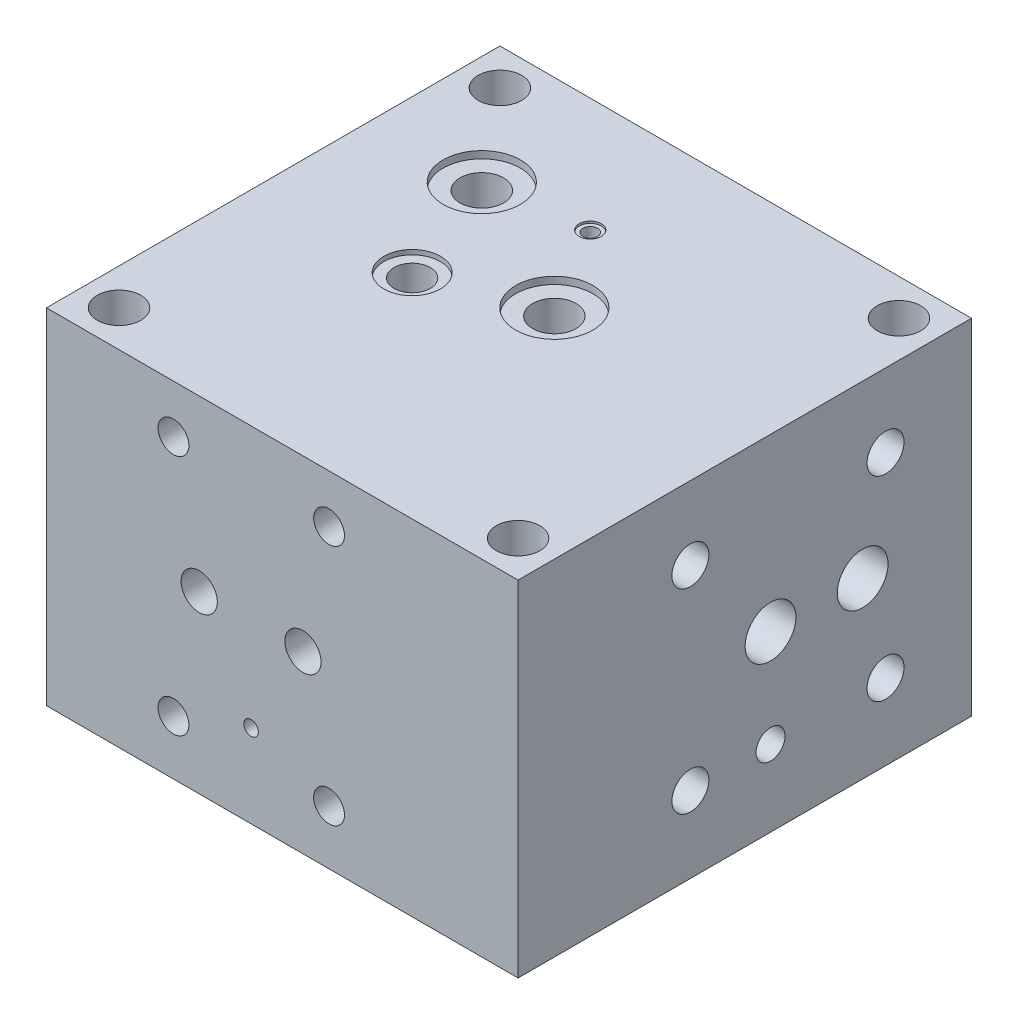
from build123d import *

# Parameters (mm, degrees)
SKETCH_1_W               = 130
SKETCH_1_H               = 125
EXTRUDE_2_DEPTH          = 95
SKETCH_2_R               = 6
CUT_EXTRUDE_1_DEPTH      = 96
SKETCH_3_R               = 6
CUT_EXTRUDE_2_DEPTH      = 95
SKETCH_4_R               = 10.65
CUT_EXTRUDE_3_DEPTH      = 1.97
SKETCH_5_R               = 6
CUT_EXTRUDE_5_DEPTH      = 94.03
SKETCH_6_R               = 10.65
CUT_EXTRUDE_6_DEPTH      = 1.97
SKETCH_7_R               = 6
CUT_EXTRUDE_7_DEPTH      = 94.03
SKETCH_8_R               = 7.8
CUT_EXTRUDE_8_DEPTH      = 1.28
MM_1_D                   = 10
MM_1_DEPTH               = 49.73
MM_1_TIP                 = 3.004303095
HOLE_WIZARD_M10_2_D      = 8.5
HOLE_WIZARD_M10_2_DEPTH  = 14
HOLE_WIZARD_M10_2_TIP    = 2.553657631
HOLE_WIZARD_M10_3_D      = 8.5
HOLE_WIZARD_M10_3_DEPTH  = 14
HOLE_WIZARD_M10_3_TIP    = 2.553657631
HOLE_WIZARD_M10_4_D      = 8.5
HOLE_WIZARD_M10_4_DEPTH  = 14
HOLE_WIZARD_M10_4_TIP    = 2.553657631
HOLE_WIZARD_M10_5_D      = 8.5
HOLE_WIZARD_M10_5_DEPTH  = 14
HOLE_WIZARD_M10_5_TIP    = 2.553657631
MM_2_D                   = 8
MM_2_DEPTH               = 10
MM_2_TIP                 = 2.403442476
CUT_EXTRUDE_9_REACH      = 132
SKETCH_17_R              = 5
MM_4_D                   = 10
MM_4_DEPTH               = 47
MM_4_TIP                 = 3.004303095
HOLE_WIZARD_M10_7_D      = 8.5
HOLE_WIZARD_M10_7_DEPTH  = 14
HOLE_WIZARD_M10_7_TIP    = 2.553657631
HOLE_WIZARD_M10_8_D      = 8.5
HOLE_WIZARD_M10_8_DEPTH  = 14
HOLE_WIZARD_M10_8_TIP    = 2.553657631
HOLE_WIZARD_M10_9_D      = 8.5
HOLE_WIZARD_M10_9_DEPTH  = 14
HOLE_WIZARD_M10_9_TIP    = 2.553657631
HOLE_WIZARD_M10_10_D     = 8.5
HOLE_WIZARD_M10_10_DEPTH = 14
HOLE_WIZARD_M10_10_TIP   = 2.553657631
CUT_EXTRUDE_10_REACH     = 127
SKETCH_27_R              = 5
CUT_EXTRUDE_11_REACH     = 127
SKETCH_28_R              = 5
HOLE_WIZARD_M12_1_D      = 10.2
HOLE_WIZARD_M12_1_DEPTH  = 18
HOLE_WIZARD_M12_1_TIP    = 3.064389157
HOLE_WIZARD_M12_2_D      = 10.2
HOLE_WIZARD_M12_2_DEPTH  = 18
HOLE_WIZARD_M12_2_TIP    = 3.064389157
HOLE_WIZARD_M12_3_D      = 10.2
HOLE_WIZARD_M12_3_DEPTH  = 18
HOLE_WIZARD_M12_3_TIP    = 3.064389157
HOLE_WIZARD_M12_4_D      = 10.2
HOLE_WIZARD_M12_4_DEPTH  = 18
HOLE_WIZARD_M12_4_TIP    = 3.064389157
MM_5_D                   = 14
MM_5_DEPTH               = 60
MM_5_TIP                 = 4.206024333
MM_6_D                   = 14
MM_6_DEPTH               = 100
MM_6_TIP                 = 4.206024333
MM_9_D                   = 8
MM_9_DEPTH               = 10
MM_9_TIP                 = 2.403442476
CUT_EXTRUDE_12_REACH     = 127
SKETCH_44_R              = 2
HOLE_WIZARD_M10_11_D     = 8.5
HOLE_WIZARD_M10_11_DEPTH = 14
HOLE_WIZARD_M10_11_TIP   = 2.553657631
SKETCH_46_R              = 3.05
CUT_EXTRUDE_13_DEPTH     = 0.56
MM_10_D                  = 4
MM_10_DEPTH              = 71
MM_10_TIP                = 1.201721238
MM_11_D                  = 4
MM_11_DEPTH              = 95
MM_11_TIP                = 1.201721238


with BuildPart() as part:
    # 草图1 → 凸台-拉伸2 (new body)
    with BuildSketch(Plane(origin=(0, 0, 0), x_dir=(1, 0, 0), z_dir=(0, 1, 0))):
        Rectangle(SKETCH_1_W, SKETCH_1_H)
    extrude(amount=EXTRUDE_2_DEPTH)

    # 草图2 → 切除-拉伸1 (cut, through all)
    with BuildSketch(Plane(origin=(0, 95, 0), x_dir=(1, 0, 0), z_dir=(0, 1, 0))):
        with Locations((-55, 52.5)):
            Circle(SKETCH_2_R)
        with Locations((55, 52.5)):
            Circle(SKETCH_2_R)
        with Locations((-55, -52.5)):
            Circle(SKETCH_2_R)
    extrude(amount=-CUT_EXTRUDE_1_DEPTH, mode=Mode.SUBTRACT)

    # 草图3 → 切除-拉伸2 (cut)
    with BuildSketch(Plane(origin=(0, 95, 0), x_dir=(1, 0, 0), z_dir=(0, 1, 0))):
        with Locations((55, -52.5)):
            Circle(SKETCH_3_R)
    extrude(amount=-CUT_EXTRUDE_2_DEPTH, mode=Mode.SUBTRACT)

    # 草图4 → 切除-拉伸3 (cut)
    with BuildSketch(Plane(origin=(0, 95, 0), x_dir=(1, 0, 0), z_dir=(0, 1, 0))):
        with Locations((-35, 27.5)):
            Circle(SKETCH_4_R)
    extrude(amount=-CUT_EXTRUDE_3_DEPTH, mode=Mode.SUBTRACT)

    # 草图5 → 切除-拉伸5 (cut, through all)
    with BuildSketch(Plane(origin=(0, 93.03, 0), x_dir=(1, 0, 0), z_dir=(0, 1, 0))):
        with Locations((-35, 27.5)):
            Circle(SKETCH_5_R)
    extrude(amount=-CUT_EXTRUDE_5_DEPTH, mode=Mode.SUBTRACT)

    # 草图6 → 切除-拉伸6 (cut)
    with BuildSketch(Plane(origin=(0, 95, 0), x_dir=(1, 0, 0), z_dir=(0, 1, 0))):
        with Locations((5, 7.5)):
            Circle(SKETCH_6_R)
    extrude(amount=-CUT_EXTRUDE_6_DEPTH, mode=Mode.SUBTRACT)

    # 草图7 → 切除-拉伸7 (cut, through all)
    with BuildSketch(Plane(origin=(0, 93.03, 0), x_dir=(1, 0, 0), z_dir=(0, 1, 0))):
        with Locations((5, 7.5)):
            Circle(SKETCH_7_R)
    extrude(amount=-CUT_EXTRUDE_7_DEPTH, mode=Mode.SUBTRACT)

    # 草图8 → 切除-拉伸8 (cut)
    with BuildSketch(Plane(origin=(0, 95, 0), x_dir=(1, 0, 0), z_dir=(0, 1, 0))):
        with Locations((-23, -3.7)):
            Circle(SKETCH_8_R)
    extrude(amount=-CUT_EXTRUDE_8_DEPTH, mode=Mode.SUBTRACT)

    # 大小mm 暗销孔1
    with Locations(Plane(origin=(-23, 93.72, 3.7), x_dir=(0, 0, 1), z_dir=(0, 1, 0))):
        with Locations((0, 0)):
            Hole(MM_1_D / 2, depth=MM_1_DEPTH)
            with Locations((0, 0, -(MM_1_DEPTH + MM_1_TIP / 2))):  # 118° drill point
                Cone(0, MM_1_D / 2, MM_1_TIP, mode=Mode.SUBTRACT)

    # M10 螺纹孔2
    with Locations(Plane(origin=(-65, 81.7, 39.4), x_dir=(0, 0, -1), z_dir=(-1, 0, 0))):
        with Locations((0, 0)):
            Hole(HOLE_WIZARD_M10_2_D / 2, depth=HOLE_WIZARD_M10_2_DEPTH)
            with Locations((0, 0, -(HOLE_WIZARD_M10_2_DEPTH + HOLE_WIZARD_M10_2_TIP / 2))):  # 118° drill point
                Cone(0, HOLE_WIZARD_M10_2_D / 2, HOLE_WIZARD_M10_2_TIP, mode=Mode.SUBTRACT)

    # M10 螺纹孔3
    with Locations(Plane(origin=(-65, 81.7, -3.5), x_dir=(0, 0, -1), z_dir=(-1, 0, 0))):
        with Locations((0, 0)):
            Hole(HOLE_WIZARD_M10_3_D / 2, depth=HOLE_WIZARD_M10_3_DEPTH)
            with Locations((0, 0, -(HOLE_WIZARD_M10_3_DEPTH + HOLE_WIZARD_M10_3_TIP / 2))):  # 118° drill point
                Cone(0, HOLE_WIZARD_M10_3_D / 2, HOLE_WIZARD_M10_3_TIP, mode=Mode.SUBTRACT)

    # M10 螺纹孔4
    with Locations(Plane(origin=(-65, 15, 39.4), x_dir=(0, 0, -1), z_dir=(-1, 0, 0))):
        with Locations((0, 0)):
            Hole(HOLE_WIZARD_M10_4_D / 2, depth=HOLE_WIZARD_M10_4_DEPTH)
            with Locations((0, 0, -(HOLE_WIZARD_M10_4_DEPTH + HOLE_WIZARD_M10_4_TIP / 2))):  # 118° drill point
                Cone(0, HOLE_WIZARD_M10_4_D / 2, HOLE_WIZARD_M10_4_TIP, mode=Mode.SUBTRACT)

    # M10 螺纹孔5
    with Locations(Plane(origin=(-65, 15, -3.5), x_dir=(0, 0, -1), z_dir=(-1, 0, 0))):
        with Locations((0, 0)):
            Hole(HOLE_WIZARD_M10_5_D / 2, depth=HOLE_WIZARD_M10_5_DEPTH)
            with Locations((0, 0, -(HOLE_WIZARD_M10_5_DEPTH + HOLE_WIZARD_M10_5_TIP / 2))):  # 118° drill point
                Cone(0, HOLE_WIZARD_M10_5_D / 2, HOLE_WIZARD_M10_5_TIP, mode=Mode.SUBTRACT)

    # 大小mm 暗销孔2
    with Locations(Plane(origin=(-65, 81.7, 12.5), x_dir=(0, 0, -1), z_dir=(-1, 0, 0))):
        with Locations((0, 0)):
            Hole(MM_2_D / 2, depth=MM_2_DEPTH)
            with Locations((0, 0, -(MM_2_DEPTH + MM_2_TIP / 2))):  # 118° drill point
                Cone(0, MM_2_D / 2, MM_2_TIP, mode=Mode.SUBTRACT)

    # 草图17 → 切除-拉伸9 (cut, up to next)
    with BuildSketch(Plane.ZY.offset(65), mode=Mode.PRIVATE) as cut_extrude_9_sk1:
        with Locations((3.7, 48.3)):
            Circle(SKETCH_17_R)
    cut_extrude_9_tool1 = extrude(cut_extrude_9_sk1.sketch, amount=-CUT_EXTRUDE_9_REACH, mode=Mode.PRIVATE) & part.part
    add(cut_extrude_9_tool1.solids().sort_by_distance((-65, 48.3, 3.7))[0], mode=Mode.SUBTRACT)

    # 大小mm 暗销孔4
    with Locations(Plane(origin=(-65, 48.3, 32.3), x_dir=(0, 0, -1), z_dir=(-1, 0, 0))):
        with Locations((0, 0)):
            Hole(MM_4_D / 2, depth=MM_4_DEPTH)
            with Locations((0, 0, -(MM_4_DEPTH + MM_4_TIP / 2))):  # 118° drill point
                Cone(0, MM_4_D / 2, MM_4_TIP, mode=Mode.SUBTRACT)

    # M10 螺纹孔7
    with Locations(Plane(origin=(12.9, 81.7, 62.5), x_dir=(1, 0, 0), z_dir=(0, 0, 1))):
        with Locations((0, 0)):
            Hole(HOLE_WIZARD_M10_7_D / 2, depth=HOLE_WIZARD_M10_7_DEPTH)
            with Locations((0, 0, -(HOLE_WIZARD_M10_7_DEPTH + HOLE_WIZARD_M10_7_TIP / 2))):  # 118° drill point
                Cone(0, HOLE_WIZARD_M10_7_D / 2, HOLE_WIZARD_M10_7_TIP, mode=Mode.SUBTRACT)

    # M10 螺纹孔8
    with Locations(Plane(origin=(-30, 81.7, 62.5), x_dir=(1, 0, 0), z_dir=(0, 0, 1))):
        with Locations((0, 0)):
            Hole(HOLE_WIZARD_M10_8_D / 2, depth=HOLE_WIZARD_M10_8_DEPTH)
            with Locations((0, 0, -(HOLE_WIZARD_M10_8_DEPTH + HOLE_WIZARD_M10_8_TIP / 2))):  # 118° drill point
                Cone(0, HOLE_WIZARD_M10_8_D / 2, HOLE_WIZARD_M10_8_TIP, mode=Mode.SUBTRACT)

    # M10 螺纹孔9
    with Locations(Plane(origin=(12.9, 15, 62.5), x_dir=(1, 0, 0), z_dir=(0, 0, 1))):
        with Locations((0, 0)):
            Hole(HOLE_WIZARD_M10_9_D / 2, depth=HOLE_WIZARD_M10_9_DEPTH)
            with Locations((0, 0, -(HOLE_WIZARD_M10_9_DEPTH + HOLE_WIZARD_M10_9_TIP / 2))):  # 118° drill point
                Cone(0, HOLE_WIZARD_M10_9_D / 2, HOLE_WIZARD_M10_9_TIP, mode=Mode.SUBTRACT)

    # M10 螺纹孔10
    with Locations(Plane(origin=(-30, 15, 62.5), x_dir=(1, 0, 0), z_dir=(0, 0, 1))):
        with Locations((0, 0)):
            Hole(HOLE_WIZARD_M10_10_D / 2, depth=HOLE_WIZARD_M10_10_DEPTH)
            with Locations((0, 0, -(HOLE_WIZARD_M10_10_DEPTH + HOLE_WIZARD_M10_10_TIP / 2))):  # 118° drill point
                Cone(0, HOLE_WIZARD_M10_10_D / 2, HOLE_WIZARD_M10_10_TIP, mode=Mode.SUBTRACT)

    # 草图27 → 切除-拉伸10 (cut, up to next)
    with BuildSketch(Plane.XY.offset(62.5), mode=Mode.PRIVATE) as cut_extrude_10_sk1:
        with Locations((-22.9, 48.3)):
            Circle(SKETCH_27_R)
    cut_extrude_10_tool1 = extrude(cut_extrude_10_sk1.sketch, amount=-CUT_EXTRUDE_10_REACH, mode=Mode.PRIVATE) & part.part
    add(cut_extrude_10_tool1.solids().sort_by_distance((-22.9, 48.3, 62.5))[0], mode=Mode.SUBTRACT)

    # 草图28 → 切除-拉伸11 (cut, up to next)
    with BuildSketch(Plane.XY.offset(62.5), mode=Mode.PRIVATE) as cut_extrude_11_sk1:
        with Locations((5.7, 48.3)):
            Circle(SKETCH_28_R)
    cut_extrude_11_tool1 = extrude(cut_extrude_11_sk1.sketch, amount=-CUT_EXTRUDE_11_REACH, mode=Mode.PRIVATE) & part.part
    add(cut_extrude_11_tool1.solids().sort_by_distance((5.7, 48.3, 62.5))[0], mode=Mode.SUBTRACT)

    # M12 螺纹孔1
    with Locations(Plane(origin=(65, 74.8, -38.8), x_dir=(0, 0, 1), z_dir=(1, 0, 0))):
        with Locations((0, 0)):
            Hole(HOLE_WIZARD_M12_1_D / 2, depth=HOLE_WIZARD_M12_1_DEPTH)
            with Locations((0, 0, -(HOLE_WIZARD_M12_1_DEPTH + HOLE_WIZARD_M12_1_TIP / 2))):  # 118° drill point
                Cone(0, HOLE_WIZARD_M12_1_D / 2, HOLE_WIZARD_M12_1_TIP, mode=Mode.SUBTRACT)

    # M12 螺纹孔2
    with Locations(Plane(origin=(65, 74.8, 15), x_dir=(0, 0, 1), z_dir=(1, 0, 0))):
        with Locations((0, 0)):
            Hole(HOLE_WIZARD_M12_2_D / 2, depth=HOLE_WIZARD_M12_2_DEPTH)
            with Locations((0, 0, -(HOLE_WIZARD_M12_2_DEPTH + HOLE_WIZARD_M12_2_TIP / 2))):  # 118° drill point
                Cone(0, HOLE_WIZARD_M12_2_D / 2, HOLE_WIZARD_M12_2_TIP, mode=Mode.SUBTRACT)

    # M12 螺纹孔3
    with Locations(Plane(origin=(65, 21, 15), x_dir=(0, 0, 1), z_dir=(1, 0, 0))):
        with Locations((0, 0)):
            Hole(HOLE_WIZARD_M12_3_D / 2, depth=HOLE_WIZARD_M12_3_DEPTH)
            with Locations((0, 0, -(HOLE_WIZARD_M12_3_DEPTH + HOLE_WIZARD_M12_3_TIP / 2))):  # 118° drill point
                Cone(0, HOLE_WIZARD_M12_3_D / 2, HOLE_WIZARD_M12_3_TIP, mode=Mode.SUBTRACT)

    # M12 螺纹孔4
    with Locations(Plane(origin=(65, 21, -38.8), x_dir=(0, 0, 1), z_dir=(1, 0, 0))):
        with Locations((0, 0)):
            Hole(HOLE_WIZARD_M12_4_D / 2, depth=HOLE_WIZARD_M12_4_DEPTH)
            with Locations((0, 0, -(HOLE_WIZARD_M12_4_DEPTH + HOLE_WIZARD_M12_4_TIP / 2))):  # 118° drill point
                Cone(0, HOLE_WIZARD_M12_4_D / 2, HOLE_WIZARD_M12_4_TIP, mode=Mode.SUBTRACT)

    # 大小mm 暗销孔5
    with Locations(Plane(origin=(65, 47.9, -7.1), x_dir=(0, 0, 1), z_dir=(1, 0, 0))):
        with Locations((0, 0)):
            Hole(MM_5_D / 2, depth=MM_5_DEPTH)
            with Locations((0, 0, -(MM_5_DEPTH + MM_5_TIP / 2))):  # 118° drill point
                Cone(0, MM_5_D / 2, MM_5_TIP, mode=Mode.SUBTRACT)

    # 大小mm 暗销孔6
    with Locations(Plane(origin=(65, 47.9, -32.5), x_dir=(0, 0, 1), z_dir=(1, 0, 0))):
        with Locations((0, 0)):
            Hole(MM_6_D / 2, depth=MM_6_DEPTH)
            with Locations((0, 0, -(MM_6_DEPTH + MM_6_TIP / 2))):  # 118° drill point
                Cone(0, MM_6_D / 2, MM_6_TIP, mode=Mode.SUBTRACT)

    # 大小mm 暗销孔9
    with Locations(Plane(origin=(65, 21, -7.1), x_dir=(0, 0, 1), z_dir=(1, 0, 0))):
        with Locations((0, 0)):
            Hole(MM_9_D / 2, depth=MM_9_DEPTH)
            with Locations((0, 0, -(MM_9_DEPTH + MM_9_TIP / 2))):  # 118° drill point
                Cone(0, MM_9_D / 2, MM_9_TIP, mode=Mode.SUBTRACT)

    # 草图44 → 切除-拉伸12 (cut, up to next)
    with BuildSketch(Plane(origin=(0, 0, -62.5), x_dir=(-1, 0, 0), z_dir=(0, 0, -1)), mode=Mode.PRIVATE) as cut_extrude_12_sk1:
        with Locations((21, 68)):
            Circle(SKETCH_44_R)
    cut_extrude_12_tool1 = extrude(cut_extrude_12_sk1.sketch, amount=-CUT_EXTRUDE_12_REACH, mode=Mode.PRIVATE) & part.part
    add(cut_extrude_12_tool1.solids().sort_by_distance((-21, 68, -62.5))[0], mode=Mode.SUBTRACT)

    # M10 螺纹孔11
    with Locations(Plane(origin=(-21, 68, -62.5), x_dir=(-1, 0, 0), z_dir=(0, 0, -1))):
        with Locations((0, 0)):
            Hole(HOLE_WIZARD_M10_11_D / 2, depth=HOLE_WIZARD_M10_11_DEPTH)
            with Locations((0, 0, -(HOLE_WIZARD_M10_11_DEPTH + HOLE_WIZARD_M10_11_TIP / 2))):  # 118° drill point
                Cone(0, HOLE_WIZARD_M10_11_D / 2, HOLE_WIZARD_M10_11_TIP, mode=Mode.SUBTRACT)

    # 草图46 → 切除-拉伸13 (cut)
    with BuildSketch(Plane(origin=(0, 95, 0), x_dir=(1, 0, 0), z_dir=(0, 1, 0))):
        with Locations((-8.6, 31)):
            Circle(SKETCH_46_R)
    extrude(amount=-CUT_EXTRUDE_13_DEPTH, mode=Mode.SUBTRACT)

    # 大小mm 暗销孔10
    with Locations(Plane(origin=(-8.6, 94.44, -31), x_dir=(0, 0, 1), z_dir=(0, 1, 0))):
        with Locations((0, 0)):
            Hole(MM_10_D / 2, depth=MM_10_DEPTH)
            with Locations((0, 0, -(MM_10_DEPTH + MM_10_TIP / 2))):  # 118° drill point
                Cone(0, MM_10_D / 2, MM_10_TIP, mode=Mode.SUBTRACT)

    # 大小mm 暗销孔11
    with Locations(Plane.XY.offset(62.5)):
        with Locations((-8.6, 22.9)):
            Hole(MM_11_D / 2, depth=MM_11_DEPTH)
            with Locations((0, 0, -(MM_11_DEPTH + MM_11_TIP / 2))):  # 118° drill point
                Cone(0, MM_11_D / 2, MM_11_TIP, mode=Mode.SUBTRACT)


solid = part.part
